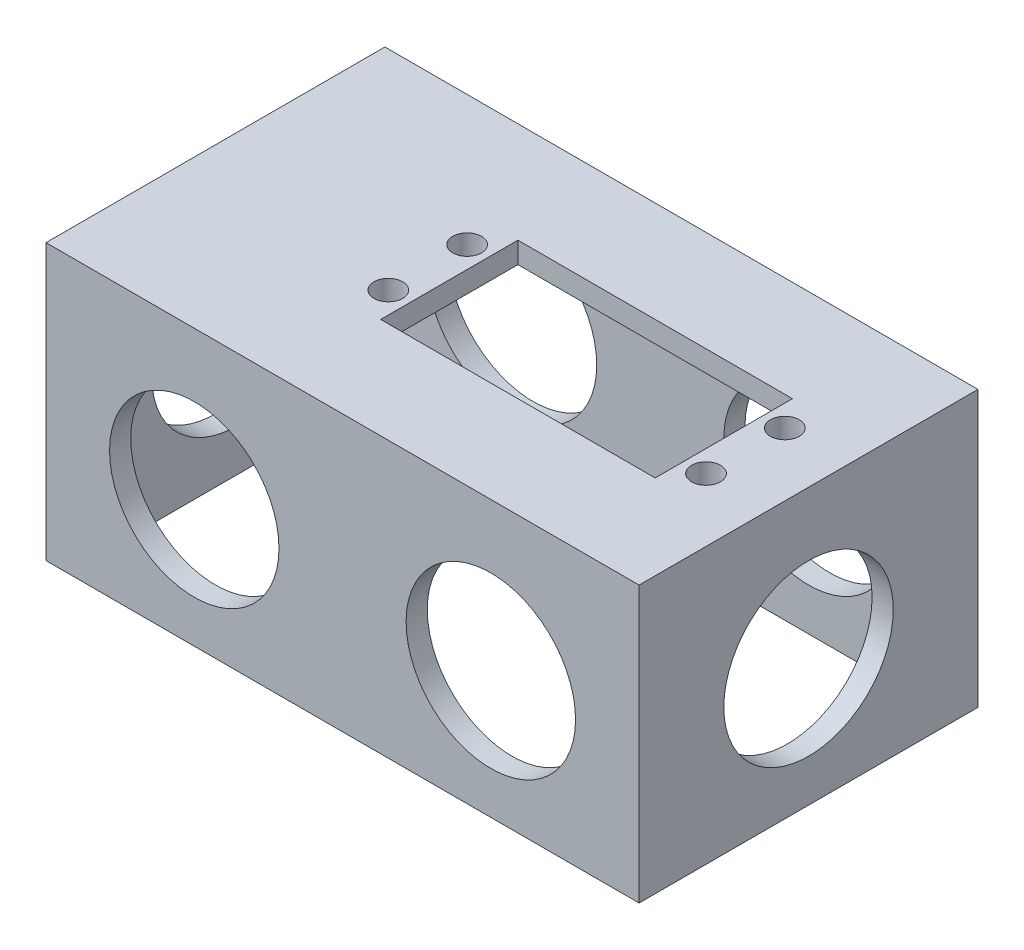
from build123d import *

# Parameters (mm, degrees)
SKETCH3_W           = 88.9
SKETCH3_H           = 50.8
SKETCH3_W_2         = 82.55
SKETCH3_H_2         = 44.45
BOSS_EXTRUDE2_DEPTH = 38.1
SKETCH4_R           = 12.7
CUT_EXTRUDE1_DEPTH  = 88.9
SKETCH6_W           = 88.9
SKETCH6_H           = 50.8
BOSS_EXTRUDE3_DEPTH = 3.175
SKETCH7_R           = 12.7
CUT_EXTRUDE2_DEPTH  = 50.8
CUT_EXTRUDE3_REACH  = 43.275
SKETCH8_R           = 2.159
SKETCH8_W           = 41.148
SKETCH8_H           = 20.574


with BuildPart() as part:
    # Sketch3 → Boss-Extrude2 (new body)
    with BuildSketch(Plane(origin=(0, 0, 0), x_dir=(1, 0, 0), z_dir=(0, 1, 0))):
        with Locations((44.45, 25.4)):
            Rectangle(SKETCH3_W, SKETCH3_H)
        with Locations((44.45, 25.4)):
            Rectangle(SKETCH3_W_2, SKETCH3_H_2, mode=Mode.SUBTRACT)
    extrude(amount=BOSS_EXTRUDE2_DEPTH)

    # Sketch4 → Cut-Extrude1 (cut)
    with BuildSketch(Plane(origin=(88.9, 0, 0), x_dir=(0, 0, -1), z_dir=(1, 0, 0))):
        with Locations((25.4, 19.05)):
            Circle(SKETCH4_R)
    extrude(amount=-CUT_EXTRUDE1_DEPTH, mode=Mode.SUBTRACT)

    # Sketch6 → Boss-Extrude3 (add)
    with BuildSketch(Plane(origin=(0, 38.1, 0), x_dir=(1, 0, 0), z_dir=(0, 1, 0))):
        with Locations((44.45, 25.4)):
            Rectangle(SKETCH6_W, SKETCH6_H)
    extrude(amount=BOSS_EXTRUDE3_DEPTH)

    # Sketch7 → Cut-Extrude2 (cut)
    with BuildSketch(Plane(origin=(0, 0, -50.8), x_dir=(-1, 0, 0), z_dir=(0, 0, -1))):
        with Locations((-66.675, 19.05)):
            Circle(SKETCH7_R)
        with Locations((-22.225, 19.05)):
            Circle(SKETCH7_R)
    extrude(amount=-CUT_EXTRUDE2_DEPTH, mode=Mode.SUBTRACT)

    # Sketch8 → Cut-Extrude3 (cut, up to next)
    with BuildSketch(Plane(origin=(0, 41.275, 0), x_dir=(1, 0, 0), z_dir=(0, 1, 0)), mode=Mode.PRIVATE) as cut_extrude3_sk1:
        with Locations((31.8135, 31.3055)):
            Circle(SKETCH8_R)
    cut_extrude3_tool1 = extrude(cut_extrude3_sk1.sketch, amount=-CUT_EXTRUDE3_REACH, mode=Mode.PRIVATE) & part.part
    add(cut_extrude3_tool1.solids().sort_by_distance((31.8135, 41.275, -31.3055))[0], mode=Mode.SUBTRACT)
    # Sketch8 → Cut-Extrude3 (cut, up to next)
    with BuildSketch(Plane(origin=(0, 41.275, 0), x_dir=(1, 0, 0), z_dir=(0, 1, 0)), mode=Mode.PRIVATE) as cut_extrude3_sk2:
        with Locations((31.8135, 19.4945)):
            Circle(SKETCH8_R)
    cut_extrude3_tool2 = extrude(cut_extrude3_sk2.sketch, amount=-CUT_EXTRUDE3_REACH, mode=Mode.PRIVATE) & part.part
    add(cut_extrude3_tool2.solids().sort_by_distance((31.8135, 41.275, -19.4945))[0], mode=Mode.SUBTRACT)
    # Sketch8 → Cut-Extrude3 (cut, up to next)
    with BuildSketch(Plane(origin=(0, 41.275, 0), x_dir=(1, 0, 0), z_dir=(0, 1, 0)), mode=Mode.PRIVATE) as cut_extrude3_sk3:
        with Locations((79.4385, 19.4945)):
            Circle(SKETCH8_R)
    cut_extrude3_tool3 = extrude(cut_extrude3_sk3.sketch, amount=-CUT_EXTRUDE3_REACH, mode=Mode.PRIVATE) & part.part
    add(cut_extrude3_tool3.solids().sort_by_distance((79.4385, 41.275, -19.4945))[0], mode=Mode.SUBTRACT)
    # Sketch8 → Cut-Extrude3 (cut, up to next)
    with BuildSketch(Plane(origin=(0, 41.275, 0), x_dir=(1, 0, 0), z_dir=(0, 1, 0)), mode=Mode.PRIVATE) as cut_extrude3_sk4:
        with Locations((79.4385, 31.3055)):
            Circle(SKETCH8_R)
    cut_extrude3_tool4 = extrude(cut_extrude3_sk4.sketch, amount=-CUT_EXTRUDE3_REACH, mode=Mode.PRIVATE) & part.part
    add(cut_extrude3_tool4.solids().sort_by_distance((79.4385, 41.275, -31.3055))[0], mode=Mode.SUBTRACT)
    # Sketch8 → Cut-Extrude3 (cut, up to next)
    with BuildSketch(Plane(origin=(0, 41.275, 0), x_dir=(1, 0, 0), z_dir=(0, 1, 0)), mode=Mode.PRIVATE) as cut_extrude3_sk5:
        with Locations((55.626, 25.4)):
            Rectangle(SKETCH8_W, SKETCH8_H)
    cut_extrude3_tool5 = extrude(cut_extrude3_sk5.sketch, amount=-CUT_EXTRUDE3_REACH, mode=Mode.PRIVATE) & part.part
    add(cut_extrude3_tool5.solids().sort_by_distance((55.626, 41.275, -25.4))[0], mode=Mode.SUBTRACT)


solid = part.part
